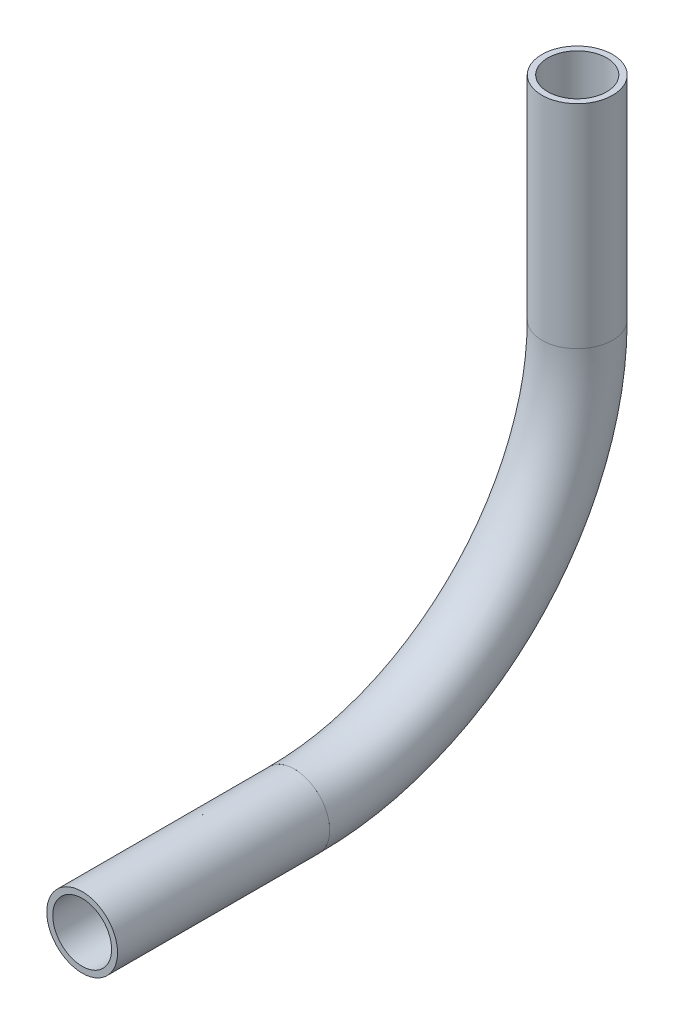
from build123d import *

# Parameters (mm, degrees)
SKETCH11_R                = 6.35
SKETCH11_R_2              = 5.2832
PIPE_0_5_SCH_40_1_DEPTH   = 38.1
SKETCH11_ON_SEGMENT_2_R   = 6.35
SKETCH11_ON_SEGMENT_2_R_2 = 5.2832
PIPE_0_5_SCH_40_1_2_ANGLE = 90
SKETCH11_ON_SEGMENT_3_R   = 6.35
SKETCH11_ON_SEGMENT_3_R_2 = 5.2832
PIPE_0_5_SCH_40_1_3_DEPTH = 38.1


with BuildPart() as part:
    # Sketch11 → Pipe 0.5 SCH 40(1) (new body)
    with BuildSketch(Plane(origin=(0, -127.073927777, 192.429076875), x_dir=(0, 0, -1), z_dir=(0, -1, 0))):
        Circle(SKETCH11_R)
        Circle(SKETCH11_R_2, mode=Mode.SUBTRACT)
    extrude(amount=PIPE_0_5_SCH_40_1_DEPTH)


with BuildPart() as body_2:
    # Sketch11 on segment 2 (carried to the start of arc 2) → Pipe 0.5 SCH 40_1 2 (revolve)
    with BuildSketch(Plane(origin=(0, -165.173927777, 192.429076875), x_dir=(0, 0, -1), z_dir=(0, -1, 0))):
        Circle(SKETCH11_ON_SEGMENT_2_R)
        Circle(SKETCH11_ON_SEGMENT_2_R_2, mode=Mode.SUBTRACT)
    revolve(axis=Axis((0, -165.173927777, 243.229076875), (-1, 0, 0)), revolution_arc=PIPE_0_5_SCH_40_1_2_ANGLE)


with BuildPart() as body_3:
    # Sketch11 on segment 3 (carried to segment 3) → Pipe 0.5 SCH 40_1 3 (new body)
    with BuildSketch(Plane(origin=(0, -215.973927777, 243.229076875), x_dir=(0, -1, 0), z_dir=(0, 0, 1))):
        Circle(SKETCH11_ON_SEGMENT_3_R)
        Circle(SKETCH11_ON_SEGMENT_3_R_2, mode=Mode.SUBTRACT)
    extrude(amount=PIPE_0_5_SCH_40_1_3_DEPTH)


solid = Compound([part.part, body_2.part, body_3.part])
